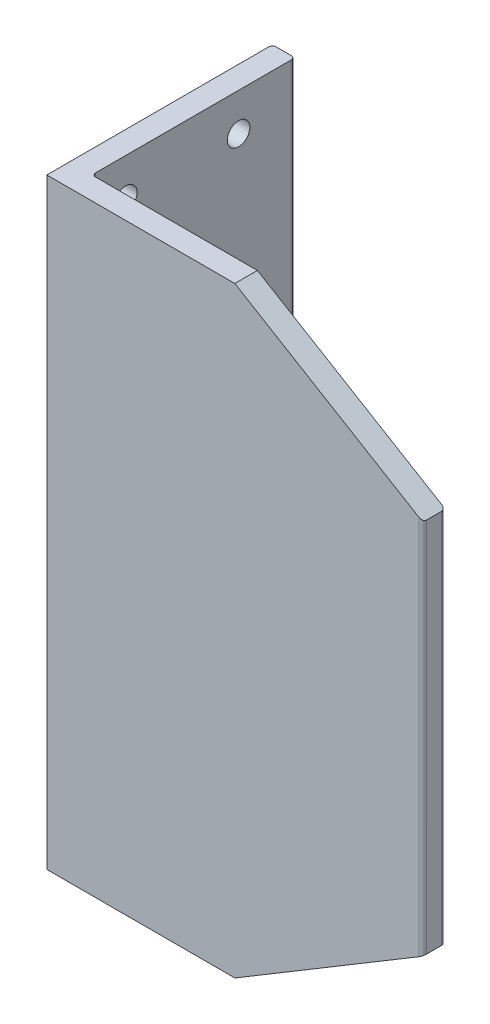
from build123d import *

# Parameters (mm, degrees)
BOSS_EXTRUDE1_DEPTH = 160
RIB6_REACH          = 143.421
SKETCH4_WALL_W      = 391.884760288
SKETCH4_WALL_H      = 6
CUT_EXTRUDE1_DEPTH  = 198.989898732
SKETCH6_R           = 3
CUT_EXTRUDE2_DEPTH  = 10


with BuildPart() as part:
    # Sketch1 → Boss-Extrude1 (new body)
    with BuildSketch(Plane(origin=(0, 0, 0), x_dir=(1, 0, 0), z_dir=(0, 1, 0))):
        with BuildLine():
            Line((0, 0), (0, 59))
            ThreePointArc((0, 59), (0.292893219, 59.707106781), (1, 60))
            Line((1, 60), (5, 60))
            ThreePointArc((5, 60), (5.707106781, 59.707106781), (6, 59))
            Line((6, 59), (6, 7))
            ThreePointArc((6, 7), (6.292893219, 6.292893219), (7, 6))
            Line((7, 6), (99, 6))
            ThreePointArc((99, 6), (99.707106781, 5.707106781), (100, 5))
            Line((100, 5), (100, 1))
            ThreePointArc((100, 1), (99.707106781, 0.292893219), (99, 0))
            Line((99, 0), (0, 0))
        make_face()
    extrude(amount=BOSS_EXTRUDE1_DEPTH)

    # Sketch4 wall → Rib6 (add, up to next)
    with BuildSketch(Plane(origin=(52.5, 80, -32.5), x_dir=(0.868817459121, 0, 0.495132530467), z_dir=(0.495132530467, 0, -0.868817459121)), mode=Mode.PRIVATE) as rib6_sk1:
        Rectangle(SKETCH4_WALL_W, SKETCH4_WALL_H)
    rib6_tool1 = extrude(rib6_sk1.sketch, amount=-RIB6_REACH, mode=Mode.PRIVATE) - part.part
    add(rib6_tool1.solids().sort_by_distance((52.5, 80, -32.5))[0])

    # Sketch5 → Cut-Extrude1 (cut, through all)
    with BuildSketch(Plane.XY):
        Polygon((100, 160), (50, 160), (100, 130), align=None)
        Polygon((100, 30), (100, 0), (50, 0), align=None)
    extrude(amount=-CUT_EXTRUDE1_DEPTH, mode=Mode.SUBTRACT)

    # Sketch6 → Cut-Extrude2 (cut)
    with BuildSketch(Plane.ZY):
        with Locations((-45, 150)):
            Circle(SKETCH6_R)
        with Locations((-15, 150)):
            Circle(SKETCH6_R)
        with Locations((-15, 10)):
            Circle(SKETCH6_R)
        with Locations((-45, 10)):
            Circle(SKETCH6_R)
    extrude(amount=-CUT_EXTRUDE2_DEPTH, mode=Mode.SUBTRACT)


solid = part.part
